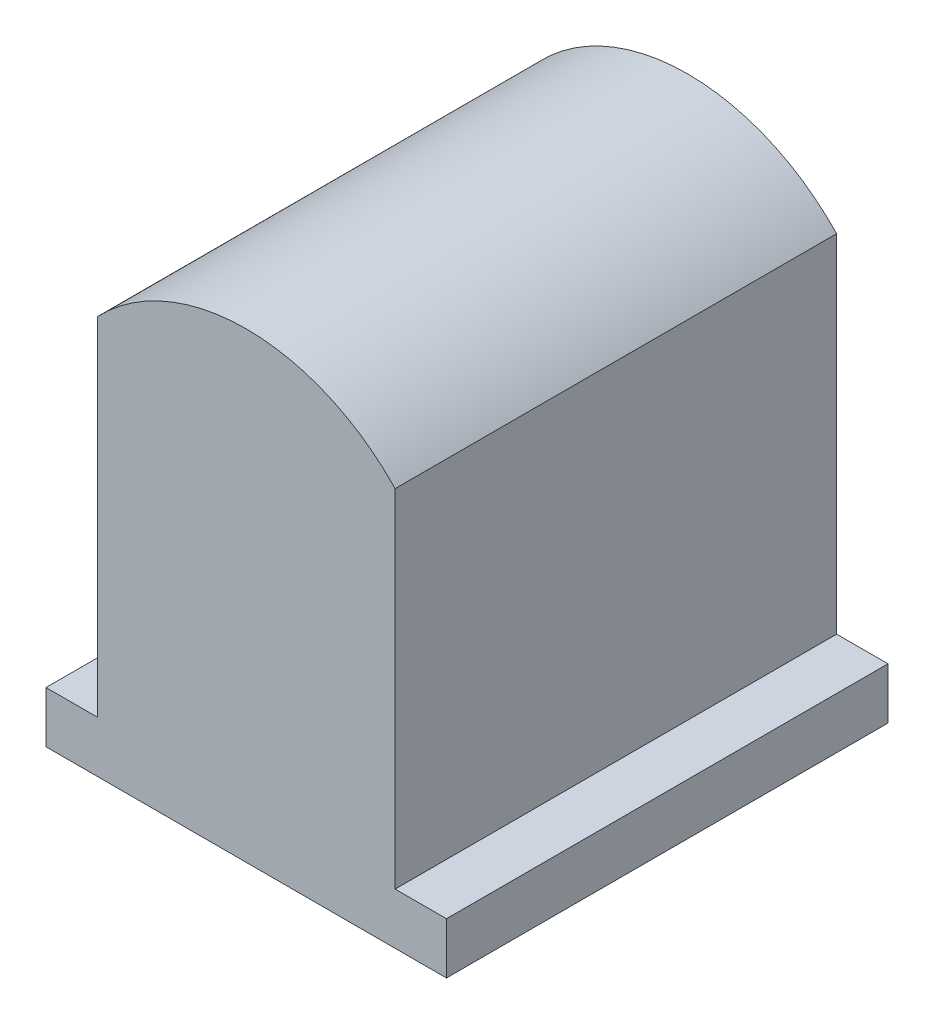
from build123d import *

# Parameters (mm, degrees)
DODANIE_WYCI_GNI_CIE1_DEPTH = 4.3


with BuildPart() as part:
    # Szkic1 → Dodanie-wyciągnięcie1 (new body)
    with BuildSketch(Plane.XY):
        with BuildLine():
            Line((-1.45, -1.438748866), (-1.95, -1.438748866))
            Line((-1.95, -1.438748866), (-1.95, -1.938748866))
            Line((-1.95, -1.938748866), (-1.45, -1.938748866))
            Line((-1.45, -1.938748866), (1.45, -1.938748866))
            Line((1.45, -1.938748866), (1.95, -1.938748866))
            Line((1.95, -1.938748866), (1.95, -1.438748866))
            Line((1.95, -1.438748866), (1.45, -1.438748866))
            Line((1.45, -1.438748866), (1.45, 1.938748866))
            ThreePointArc((1.45, 1.938748866), (0, 2.561251134), (-1.45, 1.938748866))
            Line((-1.45, 1.938748866), (-1.45, -1.438748866))
        make_face()
    extrude(amount=DODANIE_WYCI_GNI_CIE1_DEPTH)


solid = part.part
